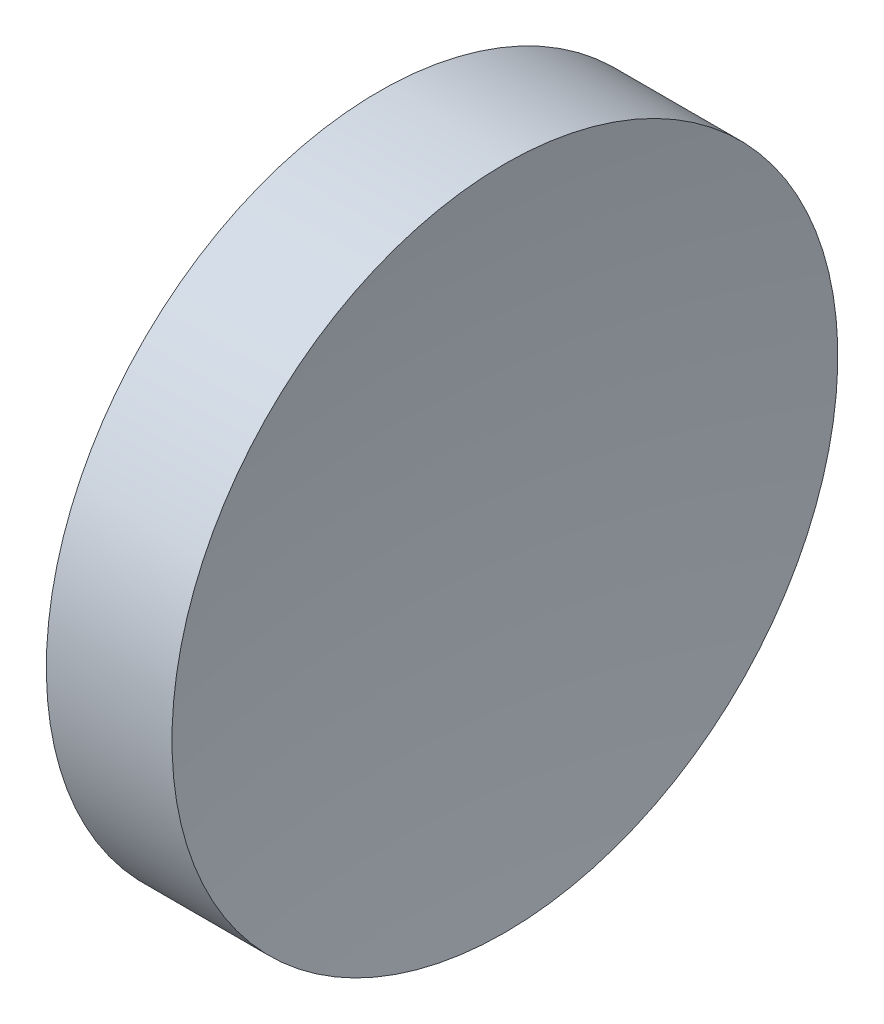
from build123d import *


with BuildPart() as part:
    # 草图1 → 旋转1 (revolve)
    with BuildSketch(Plane.XY):
        with BuildLine():
            Line((22.424232054, 13.031126091), (22.424232054, 18.031126091))
            Line((22.424232054, 18.031126091), (24.311150607, 18.031126091))
            ThreePointArc((24.311150607, 18.031126091), (24.02110607, 15.538600217), (23.924232054, 13.031126091))
            Line((23.924232054, 13.031126091), (22.424232054, 13.031126091))
        make_face()
    revolve(axis=Axis((21.505975118, 13.031126091, 0), (1, 0, 0)))


solid = part.part
